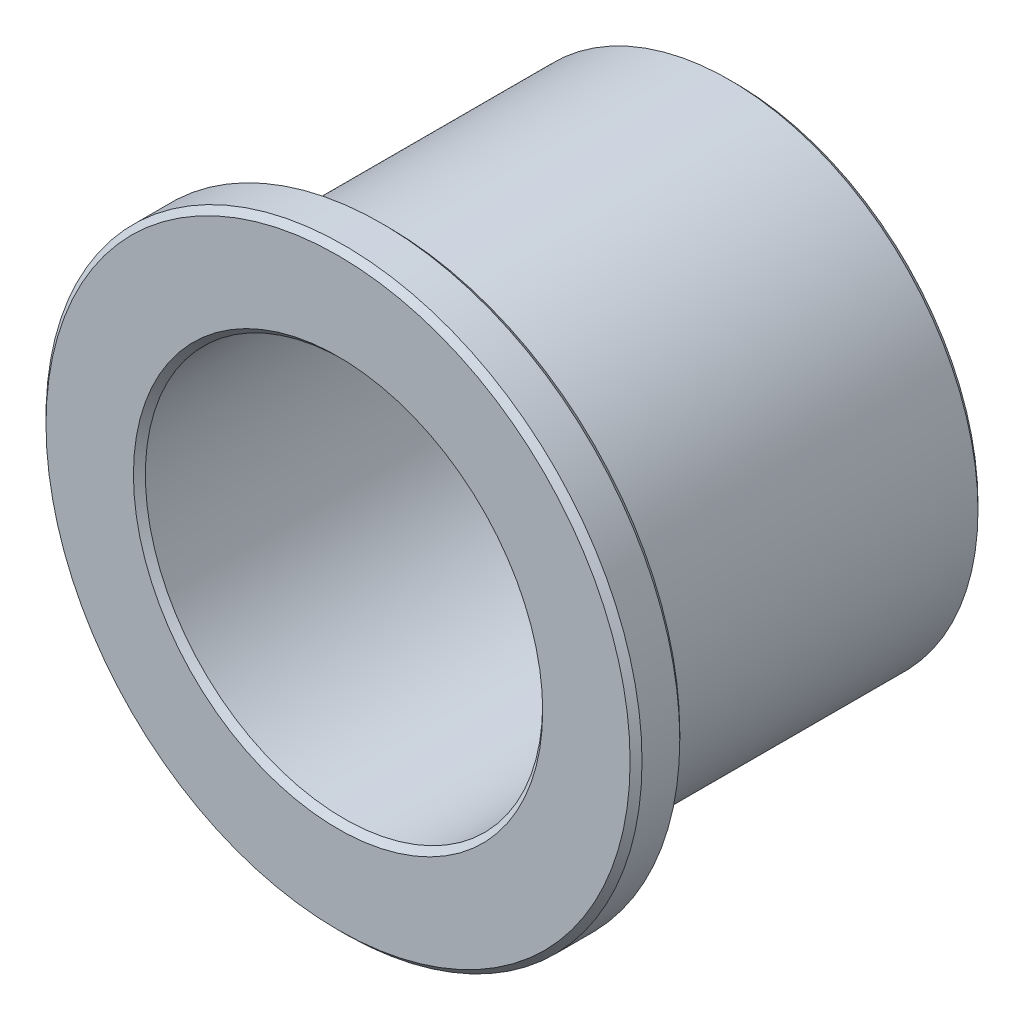
from build123d import *

# Parameters (mm, degrees)
BOSS_EXTRUDE1_START = 12.7
SKETCH3_R           = 19.05
SKETCH3_R_2         = 12.7
BOSS_EXTRUDE1_DEPTH = 3.175
BOSS_EXTRUDE2_START = 9.525
SKETCH4_R           = 15.8877
SKETCH4_R_2         = 12.7
BOSS_EXTRUDE2_DEPTH = 22.225
CHAMFER1_SIZE       = 0.381


with BuildPart() as part:
    # Sketch3 → Boss-Extrude1 (new body)
    with BuildSketch(Plane.XY.offset(BOSS_EXTRUDE1_START)):
        Circle(SKETCH3_R)
        Circle(SKETCH3_R_2, mode=Mode.SUBTRACT)
    extrude(amount=-BOSS_EXTRUDE1_DEPTH)

    # Sketch4 → Boss-Extrude2 (add)
    with BuildSketch(Plane.XY.offset(BOSS_EXTRUDE2_START)):
        Circle(SKETCH4_R)
        Circle(SKETCH4_R_2, mode=Mode.SUBTRACT)
    extrude(amount=-BOSS_EXTRUDE2_DEPTH)

    # Chamfer1
    chamfer1_edges = [part.edges().sort_by_distance(p)[0] for p in [
        (-12.7, 0, -12.7),
        (-15.8877, 0, 9.525),
        (-19.05, 0, 12.7),
        (-19.05, 0, 9.525),
        (-12.7, 0, 12.7),
        (-15.8877, 0, -12.7),
    ]]
    chamfer(chamfer1_edges, length=CHAMFER1_SIZE)


solid = part.part
